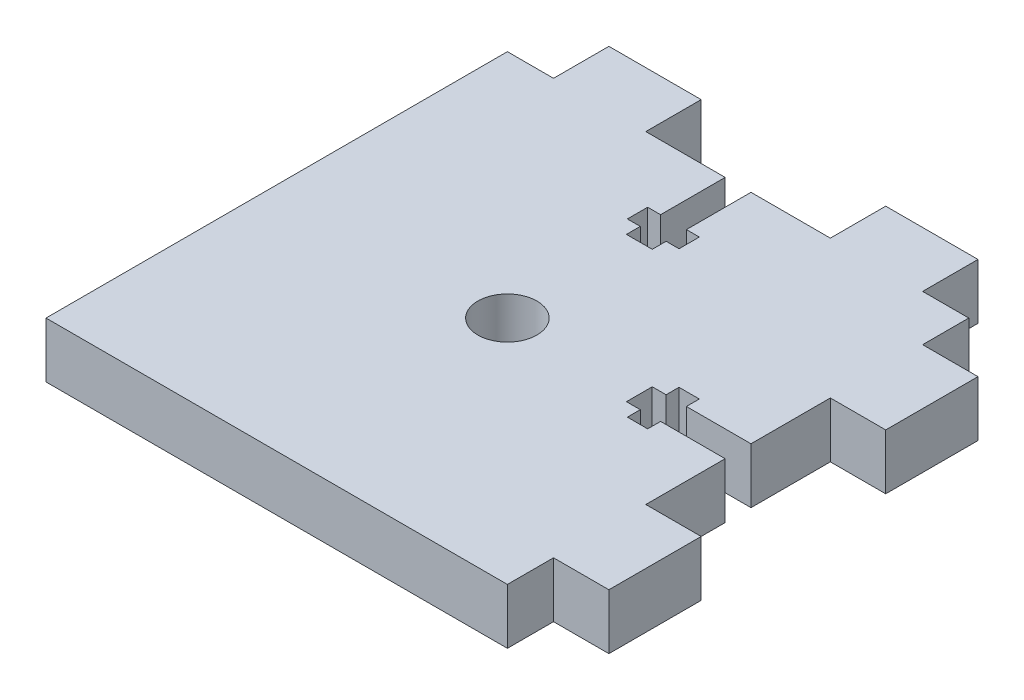
from build123d import *

# Parameters (mm, degrees)
SKETCH_1_R      = 3.2
EXTRUDE_1_DEPTH = 6


with BuildPart() as part:
    # Эскиз1 → Бобышка-Вытянуть1 (new body)
    with BuildSketch(Plane(origin=(0, 0, 0), x_dir=(1, 0, 0), z_dir=(0, 1, 0))):
        Polygon((-27.603963146, 22.034878671), (-27.603963146, -27.965121329), (22.396036854, -27.965121329), (22.396036854, -22.965121329), (28.396036854, -22.965121329), (28.396036854, -12.965121329), (22.396036854, -12.965121329), (22.396036854, -4.365121329), (15.398535816, -4.365121329), (15.398739919, -5.764951191), (13.198739556, -5.765271964), (13.197678648, -4.364354869), (11.697679078, -4.365490812), (11.695559345, -1.566408326), (13.195558915, -1.565272383), (13.194498791, -0.165391578), (15.395321341, -0.165017325), (15.395559431, -1.565121329), (22.395560638, -1.565121329), (22.395560638, 7.034878671), (28.395560638, 7.034878671), (28.395560638, 17.034878671), (22.396036854, 17.034878671), (22.396036854, 22.034878671), (17.396036854, 22.034878671), (17.396036854, 28.034878671), (7.396036854, 28.034878671), (7.396036854, 22.034618289), (-1.203963146, 22.034810758), (-1.203963146, 15.03730972), (0.194846925, 15.037513675), (0.194793578, 12.837275467), (-1.206123677, 12.836452786), (-1.20524281, 11.336452446), (-4.003305339, 11.334809299), (-4.004186206, 12.834809041), (-5.40406717, 12.833986969), (-5.40406717, 15.034809551), (-4.003963146, 15.034809551), (-4.003963146, 22.034810758), (-12.603963146, 22.034878671), (-12.603963146, 28.034878671), (-22.603963146, 28.034878671), (-22.603963146, 22.034878671), align=None)
        with Locations((-2.603963146, -2.965121329)):
            Circle(SKETCH_1_R, mode=Mode.SUBTRACT)
    extrude(amount=EXTRUDE_1_DEPTH)


solid = part.part
